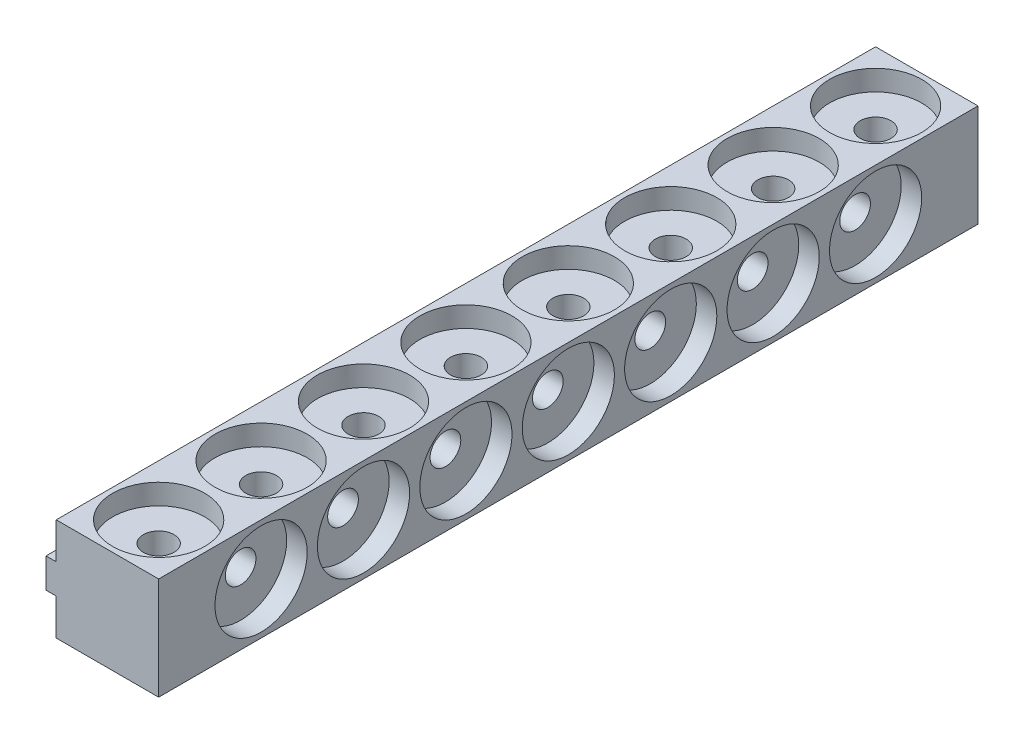
from build123d import *

# Parameters (mm, degrees)
BOSS_EXTRUDE1_DEPTH = 80
SKETCH2_R           = 1.5
CUT_EXTRUDE1_DEPTH  = 11
SKETCH3_R           = 4.5
CUT_EXTRUDE2_DEPTH  = 2
SKETCH4_R           = 1.5
CUT_EXTRUDE3_DEPTH  = 10
SKETCH6_R           = 4.5
CUT_EXTRUDE4_DEPTH  = 2
LPATTERN1_COUNT     = 8
LPATTERN1_PITCH     = 10
LPATTERN2_COUNT     = 7
LPATTERN2_PITCH     = 10


with BuildPart() as part:
    # Sketch1 → Boss-Extrude1 (new body)
    with BuildSketch(Plane.XY):
        Polygon((-10, 0), (-10, -3.55), (-11, -3.55), (-11, -6.45), (-10, -6.45), (-10, -10), (0, -10), (0, 0), align=None)
    extrude(amount=BOSS_EXTRUDE1_DEPTH)

    # Sketch2 → Cut-Extrude1 (cut, through all)
    with BuildSketch(Plane(origin=(0, 0, 0), x_dir=(1, 0, 0), z_dir=(0, 1, 0))):
        with Locations((-5, -75)):
            Circle(SKETCH2_R)
    cut_extrude1 = extrude(amount=-CUT_EXTRUDE1_DEPTH, mode=Mode.SUBTRACT)

    # Sketch3 → Cut-Extrude2 (cut)
    with BuildSketch(Plane(origin=(0, 0, 0), x_dir=(0, 0, -1), z_dir=(1, 0, 0))):
        with Locations((-70, -5)):
            Circle(SKETCH3_R)
    cut_extrude2 = extrude(amount=-CUT_EXTRUDE2_DEPTH, mode=Mode.SUBTRACT)

    # Sketch4 → Cut-Extrude3 (cut, through all)
    with BuildSketch(Plane(origin=(-2, 0, 0), x_dir=(0, 0, -1), z_dir=(1, 0, 0))):
        with Locations((-70, -5)):
            Circle(SKETCH4_R)
    cut_extrude3 = extrude(amount=-CUT_EXTRUDE3_DEPTH, mode=Mode.SUBTRACT)

    # Sketch6 → Cut-Extrude4 (cut)
    with BuildSketch(Plane(origin=(0, 0, 0), x_dir=(1, 0, 0), z_dir=(0, 1, 0))):
        with Locations((-5, -75)):
            Circle(SKETCH6_R)
    cut_extrude4 = extrude(amount=-CUT_EXTRUDE4_DEPTH, mode=Mode.SUBTRACT)

    # LPattern1: Cut-Extrude1, Cut-Extrude4 ×8
    with Locations(*[(0, 0, -i * LPATTERN1_PITCH) for i in range(1, LPATTERN1_COUNT)]):
        add(cut_extrude1, mode=Mode.SUBTRACT)
        add(cut_extrude4, mode=Mode.SUBTRACT)

    # LPattern2: Cut-Extrude2, Cut-Extrude3 ×7
    with Locations(*[(0, 0, -i * LPATTERN2_PITCH) for i in range(1, LPATTERN2_COUNT)]):
        add(cut_extrude2, mode=Mode.SUBTRACT)
        add(cut_extrude3, mode=Mode.SUBTRACT)


solid = part.part
